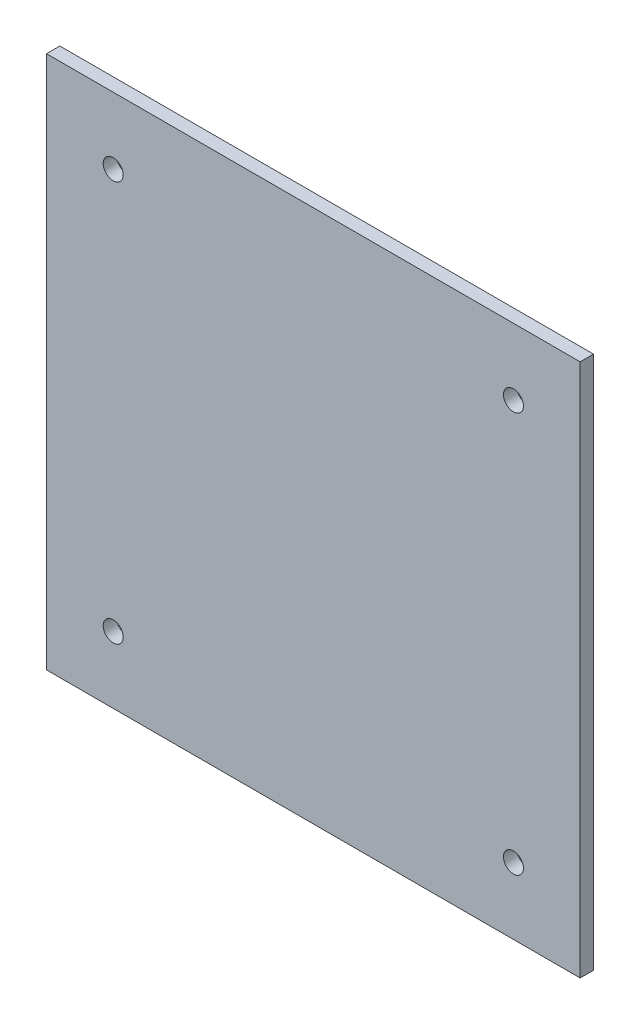
from build123d import *

# Parameters (mm, degrees)
SKETCH2_W           = 80
SKETCH2_H           = 80
BOSS_EXTRUDE1_DEPTH = 2
SKETCH3_R           = 1.5
CUT_EXTRUDE1_DEPTH  = 10


with BuildPart() as part:
    # Sketch2 → Boss-Extrude1 (new body)
    with BuildSketch(Plane.XY):
        with Locations((40, 40)):
            Rectangle(SKETCH2_W, SKETCH2_H)
    extrude(amount=BOSS_EXTRUDE1_DEPTH)

    # Sketch3 → Cut-Extrude1 (cut)
    with BuildSketch(Plane(origin=(0, 0, 0), x_dir=(-1, 0, 0), z_dir=(0, 0, -1))):
        with Locations((-70, 10)):
            Circle(SKETCH3_R)
        with Locations((-10, 10)):
            Circle(SKETCH3_R)
        with Locations((-10, 70)):
            Circle(SKETCH3_R)
        with Locations((-70, 70)):
            Circle(SKETCH3_R)
    extrude(amount=-CUT_EXTRUDE1_DEPTH, mode=Mode.SUBTRACT)


solid = part.part
